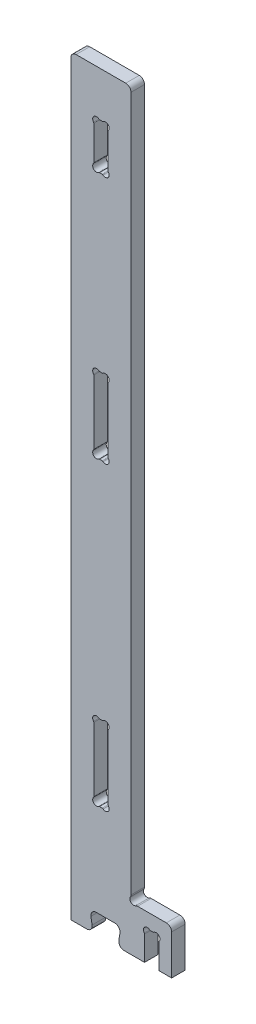
from build123d import *

# Parameters (mm, degrees)
BOSS_EXTRUDE1_DEPTH = 18
CUT_EXTRUDE1_DEPTH  = 19
CUT_EXTRUDE2_DEPTH  = 19
CUT_EXTRUDE3_DEPTH  = 19
LPATTERN1_COUNT     = 2
LPATTERN1_PITCH     = 400
FILLET1_R           = 7


with BuildPart() as part:
    # Sketch1 → Boss-Extrude1 (new body)
    with BuildSketch(Plane.XY):
        with BuildLine():
            Line((0, 0), (29.493640444, 0))
            Line((29.493640444, 0), (25.413640444, 25.5))
            Line((25.413640444, 25.5), (66.586359556, 25.5))
            Line((66.586359556, 25.5), (62.506359556, 0))
            Line((62.506359556, 0), (134, 0))
            Line((134, 0), (134, 60))
            Line((134, 60), (88.745587739, 60))
            ThreePointArc((88.745587739, 60), (87.392597488, 59.813462099), (86.140560822, 59.267766953))
            ThreePointArc((86.140560822, 59.267766953), (80, 60), (79.267766953, 66.140560822))
            ThreePointArc((79.267766953, 66.140560822), (79.813462099, 67.392597488), (80, 68.745587739))
            Line((80, 68.745587739), (80, 1000))
            Line((80, 1000), (0, 1000))
            Line((0, 1000), (0, 0))
        make_face()
    extrude(amount=BOSS_EXTRUDE1_DEPTH)

    # Sketch2 → Cut-Extrude1 (cut, through all)
    with BuildSketch(Plane.XY):
        with BuildLine():
            Line((30.5, 642.748771852), (30.5, 557.251228148))
            ThreePointArc((30.5, 557.251228148), (30.400327171, 556.660561143), (30.11234721, 556.135309084))
            ThreePointArc((30.11234721, 556.135309084), (30.5, 549.5), (37.135309084, 549.11234721))
            ThreePointArc((37.135309084, 549.11234721), (37.660561143, 549.400327171), (38.251228148, 549.5))
            Line((38.251228148, 549.5), (41.748771852, 549.5))
            ThreePointArc((41.748771852, 549.5), (42.339438857, 549.400327171), (42.864690916, 549.11234721))
            ThreePointArc((42.864690916, 549.11234721), (49.5, 549.5), (49.88765279, 556.135309084))
            ThreePointArc((49.88765279, 556.135309084), (49.599672829, 556.660561143), (49.5, 557.251228148))
            Line((49.5, 557.251228148), (49.5, 642.748771852))
            ThreePointArc((49.5, 642.748771852), (49.599672829, 643.339438857), (49.88765279, 643.864690916))
            ThreePointArc((49.88765279, 643.864690916), (49.5, 650.5), (42.864690916, 650.88765279))
            ThreePointArc((42.864690916, 650.88765279), (42.339438857, 650.599672829), (41.748771852, 650.5))
            Line((41.748771852, 650.5), (38.251228148, 650.5))
            ThreePointArc((38.251228148, 650.5), (37.660561143, 650.599672829), (37.135309084, 650.88765279))
            ThreePointArc((37.135309084, 650.88765279), (30.5, 650.5), (30.11234721, 643.864690916))
            ThreePointArc((30.11234721, 643.864690916), (30.400327171, 643.339438857), (30.5, 642.748771852))
        make_face()
    cut_extrude1 = extrude(amount=CUT_EXTRUDE1_DEPTH, mode=Mode.SUBTRACT)

    # Sketch3 → Cut-Extrude2 (cut, through all)
    with BuildSketch(Plane.XY):
        with BuildLine():
            Line((98, 0), (117, 0))
            Line((117, 0), (117, 32.748771852))
            ThreePointArc((117, 32.748771852), (117.099672829, 33.339438857), (117.38765279, 33.864690916))
            ThreePointArc((117.38765279, 33.864690916), (117, 40.5), (110.364690916, 40.88765279))
            ThreePointArc((110.364690916, 40.88765279), (109.839438857, 40.599672829), (109.248771852, 40.5))
            Line((109.248771852, 40.5), (105.751228148, 40.5))
            ThreePointArc((105.751228148, 40.5), (105.160561143, 40.599672829), (104.635309084, 40.88765279))
            ThreePointArc((104.635309084, 40.88765279), (98, 40.5), (97.61234721, 33.864690916))
            ThreePointArc((97.61234721, 33.864690916), (97.900327171, 33.339438857), (98, 32.748771852))
            Line((98, 32.748771852), (98, 0))
        make_face()
    extrude(amount=CUT_EXTRUDE2_DEPTH, mode=Mode.SUBTRACT)

    # Sketch4 → Cut-Extrude3 (cut, through all)
    with BuildSketch(Plane.XY):
        with BuildLine():
            Line((30.5, 932.748771852), (30.5, 887.251228148))
            ThreePointArc((30.5, 887.251228148), (30.400327171, 886.660561143), (30.11234721, 886.135309084))
            ThreePointArc((30.11234721, 886.135309084), (30.5, 879.5), (37.135309084, 879.11234721))
            ThreePointArc((37.135309084, 879.11234721), (37.660561143, 879.400327171), (38.251228148, 879.5))
            Line((38.251228148, 879.5), (41.748771852, 879.5))
            ThreePointArc((41.748771852, 879.5), (42.339438857, 879.400327171), (42.864690916, 879.11234721))
            ThreePointArc((42.864690916, 879.11234721), (49.5, 879.5), (49.88765279, 886.135309084))
            ThreePointArc((49.88765279, 886.135309084), (49.599672829, 886.660561143), (49.5, 887.251228148))
            Line((49.5, 887.251228148), (49.5, 932.748771852))
            ThreePointArc((49.5, 932.748771852), (49.599672829, 933.339438857), (49.88765279, 933.864690916))
            ThreePointArc((49.88765279, 933.864690916), (49.5, 940.5), (42.864690916, 940.88765279))
            ThreePointArc((42.864690916, 940.88765279), (42.339438857, 940.599672829), (41.748771852, 940.5))
            Line((41.748771852, 940.5), (38.251228148, 940.5))
            ThreePointArc((38.251228148, 940.5), (37.660561143, 940.599672829), (37.135309084, 940.88765279))
            ThreePointArc((37.135309084, 940.88765279), (30.5, 940.5), (30.11234721, 933.864690916))
            ThreePointArc((30.11234721, 933.864690916), (30.400327171, 933.339438857), (30.5, 932.748771852))
        make_face()
    extrude(amount=CUT_EXTRUDE3_DEPTH, mode=Mode.SUBTRACT)

    # LPattern1: Cut-Extrude1 ×2
    with Locations(*[(0, -i * LPATTERN1_PITCH, 0) for i in range(1, LPATTERN1_COUNT)]):
        add(cut_extrude1, mode=Mode.SUBTRACT)

    # Fillet1
    fillet1_edges = [part.edges().sort_by_distance(p)[0] for p in [
        (29.493640444, 0, 9),
        (25.413640444, 25.5, 9),
        (66.586359556, 25.5, 9),
        (62.506359556, 0, 9),
        (134, 60, 9),
        (80, 1000, 9),
        (0, 1000, 9),
    ]]
    fillet(fillet1_edges, radius=FILLET1_R)


solid = part.part
